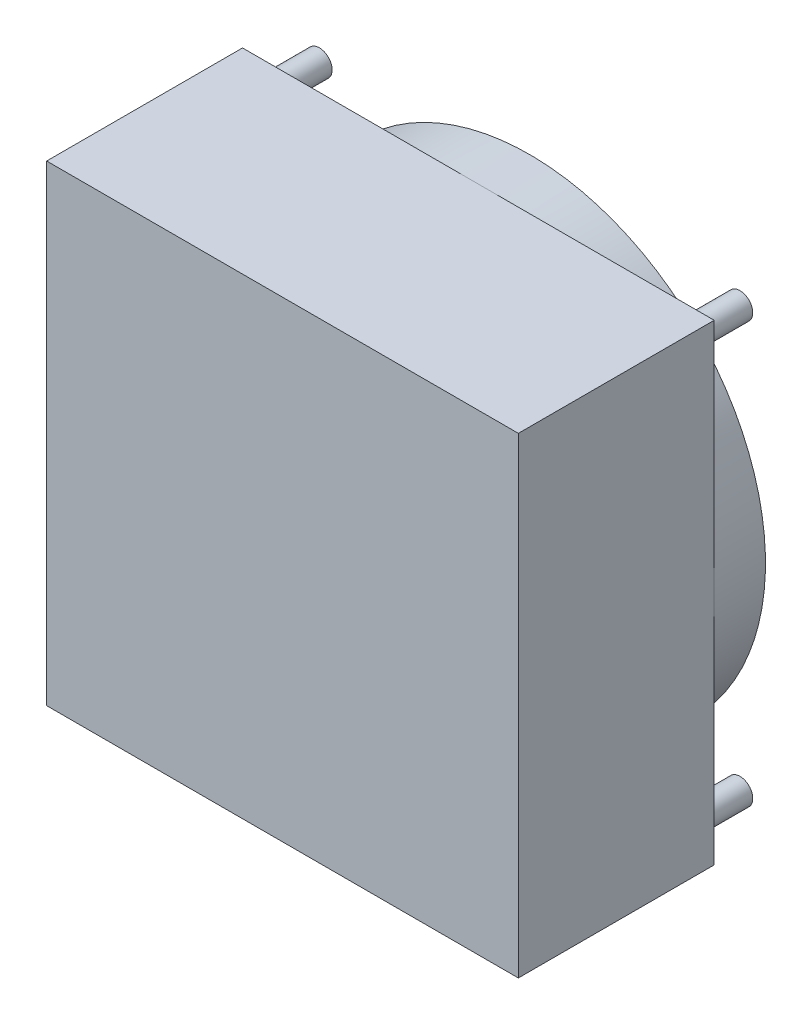
from build123d import *

# Parameters (mm, degrees)
SKETCH2_W           = 92
SKETCH2_H           = 92
BOSS_EXTRUDE1_DEPTH = 38.2
SKETCH3_R           = 2.5
BOSS_EXTRUDE2_DEPTH = 10
SKETCH4_R           = 46
BOSS_EXTRUDE3_DEPTH = 10


with BuildPart() as part:
    # Sketch2 → Boss-Extrude1 (new body)
    with BuildSketch(Plane.XY):
        with Locations((46, 46)):
            Rectangle(SKETCH2_W, SKETCH2_H)
    extrude(amount=BOSS_EXTRUDE1_DEPTH)

    # Sketch3 → Boss-Extrude2 (add)
    with BuildSketch(Plane(origin=(0, 0, 0), x_dir=(-1, 0, 0), z_dir=(0, 0, -1))):
        with Locations((-4.98, 4.98)):
            Circle(SKETCH3_R)
        with Locations((-87.02, 4.98)):
            Circle(SKETCH3_R)
        with Locations((-87.02, 87.02)):
            Circle(SKETCH3_R)
        with Locations((-4.98, 87.02)):
            Circle(SKETCH3_R)
    extrude(amount=BOSS_EXTRUDE2_DEPTH)

    # Sketch4 → Boss-Extrude3 (add)
    with BuildSketch(Plane(origin=(0, 0, 0), x_dir=(-1, 0, 0), z_dir=(0, 0, -1))):
        with Locations((-46, 46)):
            Circle(SKETCH4_R)
    extrude(amount=BOSS_EXTRUDE3_DEPTH)


solid = part.part
